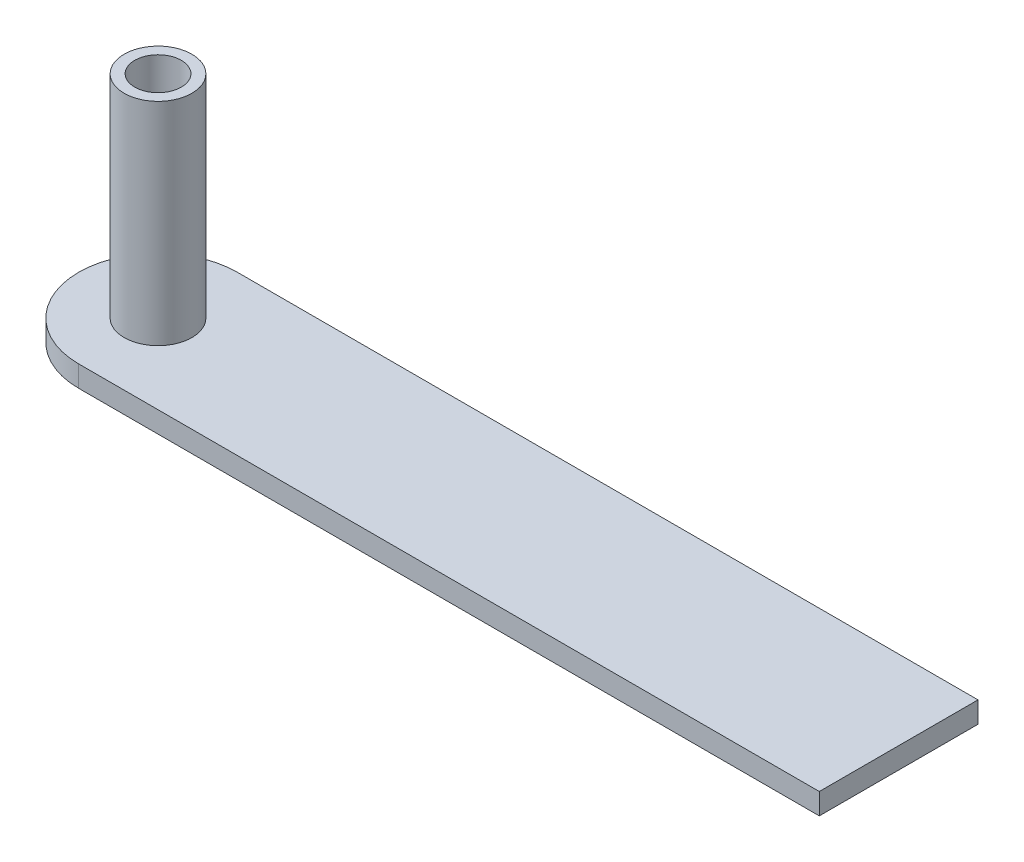
from build123d import *

# Parameters (mm, degrees)
SKETCH1_W           = 70
SKETCH1_H           = 15
BOSS_EXTRUDE1_DEPTH = 2
BOSS_EXTRUDE2_START = -2
SKETCH2_R           = 7.5
BOSS_EXTRUDE2_DEPTH = 2
SKETCH3_R           = 3.2
SKETCH3_R_2         = 2.4
BOSS_EXTRUDE5_DEPTH = 20
SKETCH10_R          = 2.4
CUT_EXTRUDE1_DEPTH  = 16
SKETCH11_R          = 3.2
SKETCH11_R_2        = 2.199750497
BOSS_EXTRUDE6_DEPTH = 22
SKETCH12_R          = 2.2
SKETCH12_R_2        = 2
BOSS_EXTRUDE8_DEPTH = 22
SKETCH13_R          = 2.2
CUT_EXTRUDE2_DEPTH  = 4
SKETCH14_R          = 2.5
SKETCH14_R_2        = 2
CUT_EXTRUDE4_DEPTH  = 17


with BuildPart() as part:
    # Sketch1 → Boss-Extrude1 (new body)
    with BuildSketch(Plane(origin=(0, 0, 0), x_dir=(1, 0, 0), z_dir=(0, 1, 0))):
        with Locations((35, 7.5)):
            Rectangle(SKETCH1_W, SKETCH1_H)
    extrude(amount=BOSS_EXTRUDE1_DEPTH)

    # Sketch2 → Boss-Extrude2 (add)
    with BuildSketch(Plane(origin=(0, 2, 0), x_dir=(1, 0, 0), z_dir=(0, 1, 0)).offset(BOSS_EXTRUDE2_START)):
        with Locations((0, 7.5)):
            Circle(SKETCH2_R)
    extrude(amount=BOSS_EXTRUDE2_DEPTH)

    # Sketch3 → Boss-Extrude5 (add)
    with BuildSketch(Plane(origin=(0, 2, 0), x_dir=(1, 0, 0), z_dir=(0, 1, 0))):
        with Locations((0, 7.5)):
            Circle(SKETCH3_R)
        with Locations((0, 7.5)):
            Circle(SKETCH3_R_2, mode=Mode.SUBTRACT)
    extrude(amount=BOSS_EXTRUDE5_DEPTH)

    # Sketch10 → Cut-Extrude1 (cut)
    with BuildSketch(Plane(origin=(0, 2, 0), x_dir=(1, 0, 0), z_dir=(0, 1, 0))):
        with Locations((0, 7.5)):
            Circle(SKETCH10_R)
    extrude(amount=-CUT_EXTRUDE1_DEPTH, mode=Mode.SUBTRACT)

    # Sketch11 → Boss-Extrude6 (add)
    with BuildSketch(Plane(origin=(0, 22, 0), x_dir=(1, 0, 0), z_dir=(0, 1, 0))):
        with Locations((0, 7.5)):
            Circle(SKETCH11_R)
        with Locations((0, 7.5)):
            Circle(SKETCH11_R_2, mode=Mode.SUBTRACT)
    extrude(amount=-BOSS_EXTRUDE6_DEPTH)

    # Sketch12 → Boss-Extrude8 (add)
    with BuildSketch(Plane(origin=(0, 22, 0), x_dir=(1, 0, 0), z_dir=(0, 1, 0))):
        with Locations((0, 7.5)):
            Circle(SKETCH12_R)
        with Locations((0, 7.5)):
            Circle(SKETCH12_R_2, mode=Mode.SUBTRACT)
    extrude(amount=-BOSS_EXTRUDE8_DEPTH)

    # Sketch13 → Cut-Extrude2 (cut)
    with BuildSketch(Plane(origin=(0, 22, 0), x_dir=(1, 0, 0), z_dir=(0, 1, 0))):
        with Locations((0, 7.5)):
            Circle(SKETCH13_R)
    extrude(amount=-CUT_EXTRUDE2_DEPTH, mode=Mode.SUBTRACT)

    # Sketch14 → Cut-Extrude4 (cut)
    with BuildSketch(Plane.XZ):
        with Locations((0, -7.5)):
            Circle(SKETCH14_R)
        with Locations((0, -7.5)):
            Circle(SKETCH14_R_2, mode=Mode.SUBTRACT)
    extrude(amount=-CUT_EXTRUDE4_DEPTH, mode=Mode.SUBTRACT)


solid = part.part
